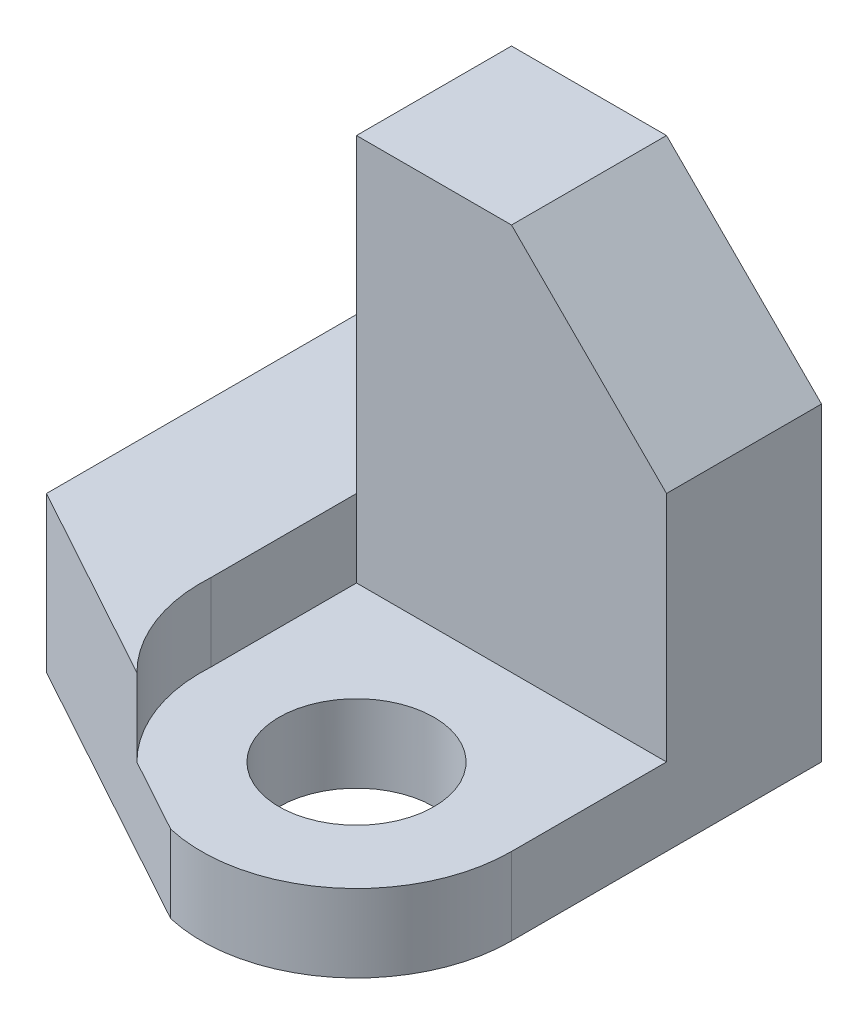
from build123d import *

# Parameters (mm, degrees)
SKETCH1_R           = 1
BOSS_EXTRUDE1_DEPTH = 2
CUT_EXTRUDE1_DEPTH  = 1
SKETCH3_W           = 4
SKETCH3_H           = 2
BOSS_EXTRUDE2_DEPTH = 5
CHAMFER1_SIZE       = 2


with BuildPart() as part:
    # Sketch1 → Boss-Extrude1 (new body)
    with BuildSketch(Plane(origin=(0, 0, 0), x_dir=(1, 0, 0), z_dir=(0, 1, 0))):
        with BuildLine():
            Line((0, -4), (0, 0))
            Line((0, 0), (-2, 0))
            Line((-2, 0), (-2, -4))
            Line((-2, -4), (0.596081752, -5.424434468))
            ThreePointArc((0.596081752, -5.424434468), (0.15502893, -4.772063308), (0, -4))
        make_face()
        with BuildLine():
            Line((4, 0), (0, 0))
            Line((0, 0), (0, -4))
            ThreePointArc((0, -4), (0.15502893, -4.772063308), (0.596081752, -5.424434468))
            Line((0.596081752, -5.424434468), (1.552766589, -5.949354323))
            ThreePointArc((1.552766589, -5.949354323), (3.246100553, -5.56436358), (4, -4))
            Line((4, -4), (4, 0))
        make_face()
        with Locations((2, -4)):
            Circle(SKETCH1_R, mode=Mode.SUBTRACT)
    extrude(amount=BOSS_EXTRUDE1_DEPTH)

    # Sketch2 → Cut-Extrude1 (cut)
    with BuildSketch(Plane(origin=(0, 2, 0), x_dir=(1, 0, 0), z_dir=(0, 1, 0))):
        with BuildLine():
            Line((0, 0), (4, 0))
            Line((4, 0), (4, -4))
            ThreePointArc((4, -4), (1.935634166, -6.000972869), (0, -3.875221449))
            Line((0, -3.875221449), (0, 0))
        make_face()
    extrude(amount=-CUT_EXTRUDE1_DEPTH, mode=Mode.SUBTRACT)

    # Sketch3 → Boss-Extrude2 (add)
    with BuildSketch(Plane(origin=(0, 1, 0), x_dir=(1, 0, 0), z_dir=(0, 1, 0))):
        with Locations((2, -1)):
            Rectangle(SKETCH3_W, SKETCH3_H)
    extrude(amount=BOSS_EXTRUDE2_DEPTH)

    # Chamfer1
    chamfer1_edges = [part.edges().sort_by_distance(p)[0] for p in [
        (4, 6, 1),
    ]]
    chamfer(chamfer1_edges, length=CHAMFER1_SIZE)


solid = part.part
